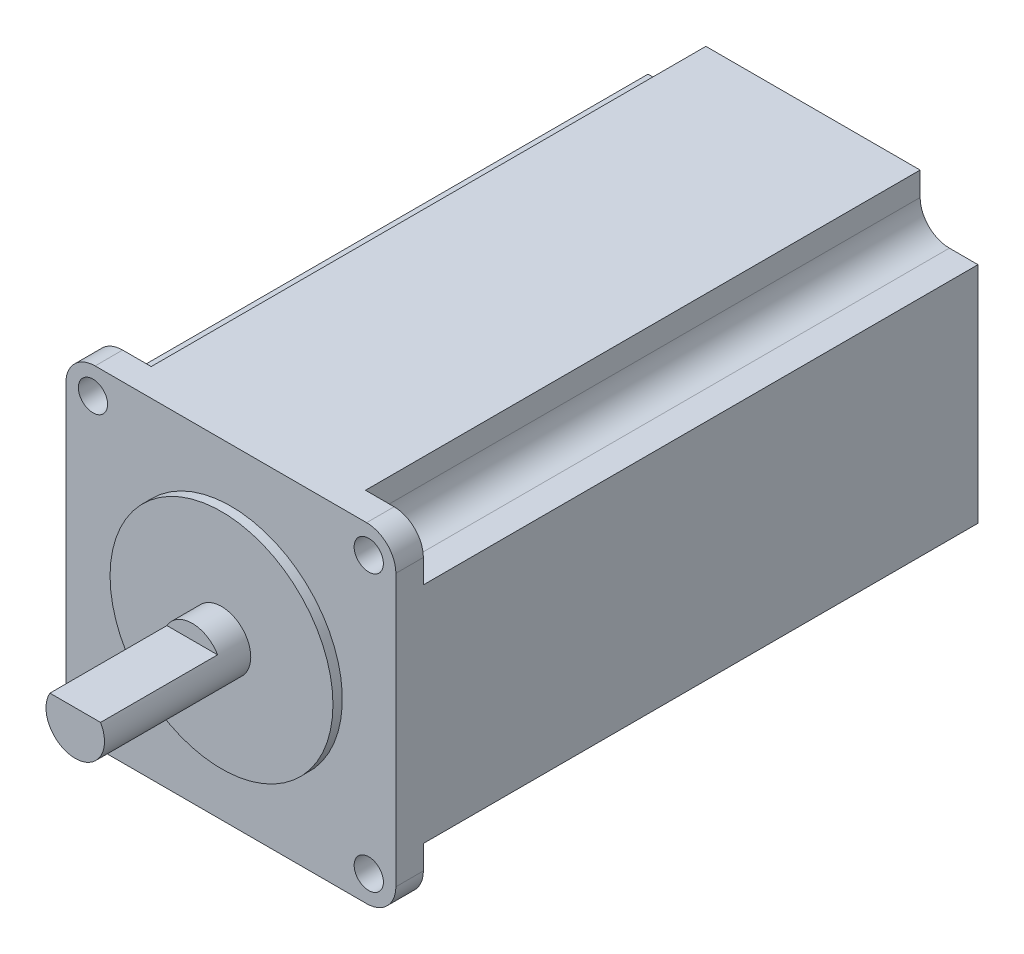
from build123d import *

# Parameters (mm, degrees)
SKETCH_1_W          = 56.4
SKETCH_1_H          = 56.4
EXTRUDE_1_DEPTH     = 99.5
SKETCH_2_R          = 19.05
EXTRUDE_2_DEPTH     = 1.6
SKETCH_3_R          = 5
EXTRUDE_3_DEPTH     = 25
SKETCH_4_W          = 8.660254038
SKETCH_4_H          = 6.0292226
CUT_EXTRUDE_1_DEPTH = 20
CUT_EXTRUDE_2_DEPTH = 94.8
SKETCH_6_R          = 2.5
CUT_EXTRUDE_3_DEPTH = 94.8
FILLET_1_R          = 5


with BuildPart() as part:
    # 草图1 → 凸台-拉伸1 (new body)
    with BuildSketch(Plane.XY):
        with Locations((28.2, 28.2)):
            Rectangle(SKETCH_1_W, SKETCH_1_H)
    extrude(amount=EXTRUDE_1_DEPTH)

    # 草图2 → 凸台-拉伸2 (add)
    with BuildSketch(Plane.XY.offset(99.5)):
        with Locations((28.2, 28.2)):
            Circle(SKETCH_2_R)
    extrude(amount=EXTRUDE_2_DEPTH)

    # 草图3 → 凸台-拉伸3 (add)
    with BuildSketch(Plane.XY.offset(101.1)):
        with Locations((28.2, 28.2)):
            Circle(SKETCH_3_R)
    extrude(amount=EXTRUDE_3_DEPTH)

    # 草图4 → 切除-拉伸1 (cut)
    with BuildSketch(Plane.XY.offset(126.1)):
        with Locations((28.2, 33.7146113)):
            Rectangle(SKETCH_4_W, SKETCH_4_H)
    extrude(amount=-CUT_EXTRUDE_1_DEPTH, mode=Mode.SUBTRACT)

    # 草图5 → 切除-拉伸2 (cut)
    with BuildSketch(Plane(origin=(0, 0, 0), x_dir=(-1, 0, 0), z_dir=(0, 0, -1))):
        with BuildLine():
            Line((-61.988810655, 58.062513104), (-46.510137618, 58.062513104))
            Line((-46.510137618, 58.062513104), (-46.510137618, 52.340700561))
            ThreePointArc((-46.510137618, 52.340700561), (-47.974603712, 48.805166655), (-51.510137618, 47.340700561))
            Line((-51.510137618, 47.340700561), (-61.988810655, 47.340700561))
            Line((-61.988810655, 47.340700561), (-61.988810655, 58.062513104))
        make_face()
        with BuildLine():
            Line((-9.889862382, 58.062513104), (-9.889862382, 52.340700561))
            ThreePointArc((-9.889862382, 52.340700561), (-8.425396288, 48.805166655), (-4.889862382, 47.340700561))
            Line((-4.889862382, 47.340700561), (5.588810655, 47.340700561))
            Line((5.588810655, 47.340700561), (5.588810655, 58.062513104))
            Line((5.588810655, 58.062513104), (-9.889862382, 58.062513104))
        make_face()
        with BuildLine():
            Line((5.588810655, -1.662513104), (-9.889862382, -1.662513104))
            Line((-9.889862382, -1.662513104), (-9.889862382, 4.059299439))
            ThreePointArc((-9.889862382, 4.059299439), (-8.425396288, 7.594833345), (-4.889862382, 9.059299439))
            Line((-4.889862382, 9.059299439), (5.588810655, 9.059299439))
            Line((5.588810655, 9.059299439), (5.588810655, -1.662513104))
        make_face()
        with BuildLine():
            Line((-46.510137618, -1.662513104), (-46.510137618, 4.059299439))
            ThreePointArc((-46.510137618, 4.059299439), (-47.974603712, 7.594833345), (-51.510137618, 9.059299439))
            Line((-51.510137618, 9.059299439), (-61.988810655, 9.059299439))
            Line((-61.988810655, 9.059299439), (-61.988810655, -1.662513104))
            Line((-61.988810655, -1.662513104), (-46.510137618, -1.662513104))
        make_face()
    extrude(amount=-CUT_EXTRUDE_2_DEPTH, mode=Mode.SUBTRACT)

    # 草图6 → 切除-拉伸3 (cut)
    with BuildSketch(Plane.XY.offset(99.5)):
        with Locations((4.63, 51.77)):
            Circle(SKETCH_6_R)
        with Locations((51.77, 51.77)):
            Circle(SKETCH_6_R)
        with Locations((51.77, 4.63)):
            Circle(SKETCH_6_R)
        with Locations((4.63, 4.63)):
            Circle(SKETCH_6_R)
    extrude(amount=-CUT_EXTRUDE_3_DEPTH, mode=Mode.SUBTRACT)

    # 圆角1
    fillet_1_edges = [part.edges().sort_by_distance(p)[0] for p in [
        (0, 56.4, 97.15),
        (56.4, 56.4, 97.15),
        (56.4, 0, 97.15),
        (0, 0, 97.15),
    ]]
    fillet(fillet_1_edges, radius=FILLET_1_R)


solid = part.part
